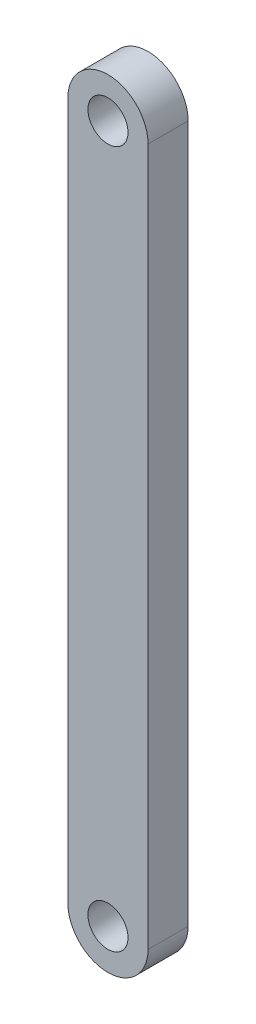
from build123d import *

# Parameters (mm, degrees)
SKETCH1_R           = 3.175
BOSS_EXTRUDE1_DEPTH = 6.35


with BuildPart() as part:
    # Sketch1 → Boss-Extrude1 (new body)
    with BuildSketch(Plane.XY):
        with BuildLine():
            Line((-6.35, 110.49), (-6.35, 0))
            ThreePointArc((-6.35, 0), (0, -6.35), (6.35, 0))
            Line((6.35, 0), (6.35, 110.49))
            ThreePointArc((6.35, 110.49), (0, 116.84), (-6.35, 110.49))
        make_face()
        with Locations((0, 110.49)):
            Circle(SKETCH1_R, mode=Mode.SUBTRACT)
        Circle(SKETCH1_R, mode=Mode.SUBTRACT)
    extrude(amount=BOSS_EXTRUDE1_DEPTH)


solid = part.part
